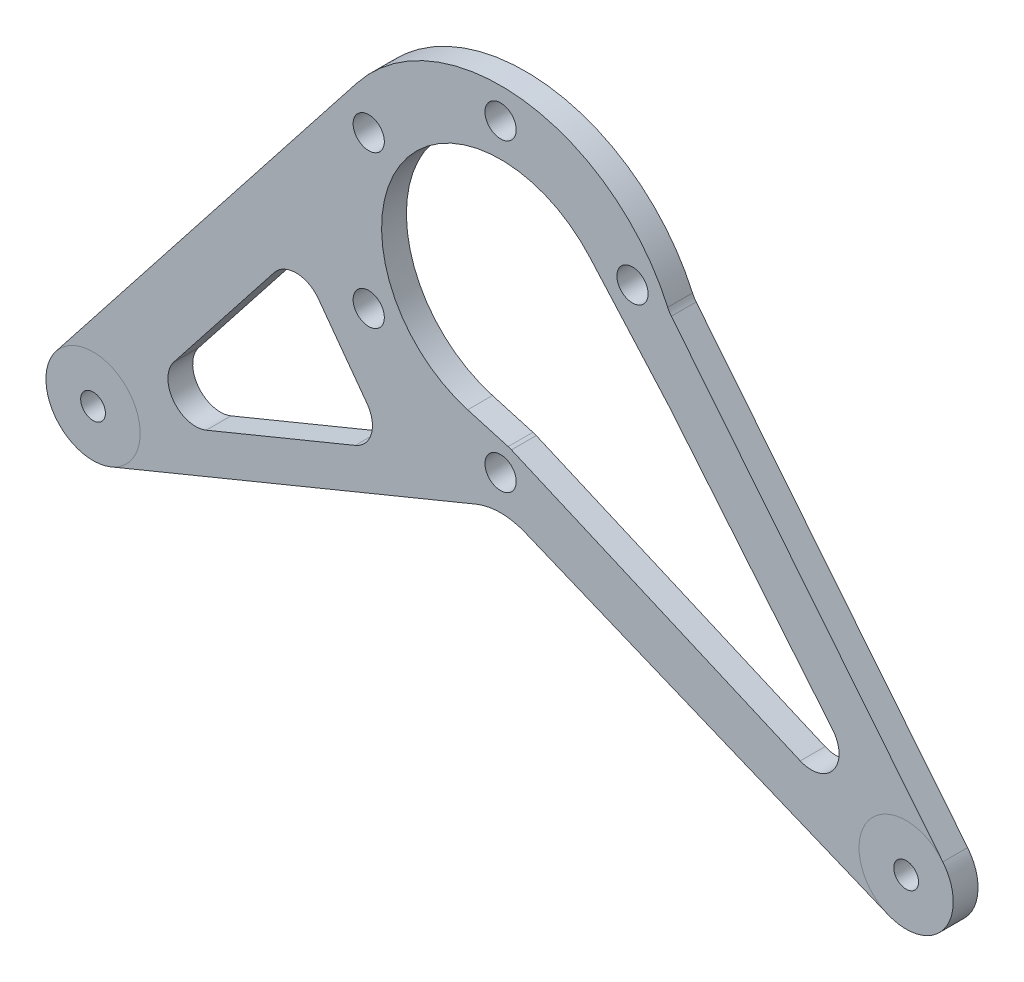
from build123d import *

# Parameters (mm, degrees)
SKETCH3_R           = 4
SKETCH3_R_2         = 3.175
BOSS_EXTRUDE1_DEPTH = 6.35


with BuildPart() as part:
    # Sketch3 → Boss-Extrude1 (new body)
    with BuildSketch(Plane.XY):
        with BuildLine():
            ThreePointArc((-54.344755215, 14.159551399), (-91.363790432, 41.595955293), (-133.974414464, 24.060278895))
            Line((-133.974414464, 24.060278895), (-211.005412605, -73.916742383))
            ThreePointArc((-211.005412605, -73.916742383), (-211.144018552, -88.650897892), (-196.929213693, -92.530829979))
            Line((-196.929213693, -92.530829979), (-103.422476429, -54.04933414))
            ThreePointArc((-103.422476429, -54.04933414), (-97.145595861, -52.808695879), (-90.869059624, -54.05107498))
            Line((-90.869059624, -54.05107498), (2.122974069, -92.350913963))
            ThreePointArc((2.122974069, -92.350913963), (16.383743715, -88.415214787), (16.111301916, -73.623830322))
            Line((16.111301916, -73.623830322), (-53.413545275, 12.636035393))
            ThreePointArc((-53.413545275, 12.636035393), (-53.928639798, 13.36754418), (-54.344755215, 14.159551399))
        make_face()
        with BuildLine():
            ThreePointArc((-94.365331084, -37.471342529), (-94.782391681, -37.306590994), (-95.20914515, -37.168880842))
            Line((-95.20914515, -37.168880842), (-105.570837866, -34.188121867))
            ThreePointArc((-105.570837866, -34.188121867), (-122.920802355, 11.370636159), (-74.330134016, 15.316349154))
            Line((-74.330134016, 15.316349154), (-54.078953085, -7.541638988))
            ThreePointArc((-54.078953085, -7.541638988), (-54.00749546, -7.623730088), (-53.937484416, -7.707058323))
            Line((-53.937484416, -7.707058323), (-12.08621589, -58.41284178))
            ThreePointArc((-12.08621589, -58.41284178), (-11.885929876, -67.212968778), (-20.394707026, -69.467533275))
            Line((-20.394707026, -69.467533275), (-94.365331084, -37.471342529))
        make_face(mode=Mode.SUBTRACT)
        with BuildLine():
            ThreePointArc((-172.528906448, -72.18914022), (-180.908159839, -69.902022358), (-180.826455281, -61.216625426))
            Line((-180.826455281, -61.216625426), (-155.117076369, -28.516434264))
            ThreePointArc((-155.117076369, -28.516434264), (-149.40547172, -25.801135391), (-143.78928279, -28.708659687))
            Line((-143.78928279, -28.708659687), (-131.33676671, -45.703813477))
            ThreePointArc((-131.33676671, -45.703813477), (-130.226967626, -51.831800551), (-134.367011458, -56.484102848))
            Line((-134.367011458, -56.484102848), (-172.528906448, -72.18914022))
        make_face(mode=Mode.SUBTRACT)
        with Locations((-130.919350653, -24.396060329)):
            Circle(SKETCH3_R, mode=Mode.SUBTRACT)
        with Locations((-97.144359905, -43.896060329)):
            Circle(SKETCH3_R, mode=Mode.SUBTRACT)
        with Locations((-130.919350653, 14.603939671)):
            Circle(SKETCH3_R, mode=Mode.SUBTRACT)
        with Locations((-63.369369158, 14.603939671)):
            Circle(SKETCH3_R, mode=Mode.SUBTRACT)
        with Locations((-97.144359905, 34.103939671)):
            Circle(SKETCH3_R, mode=Mode.SUBTRACT)
        with Locations((6.717643784, -81.195052938)):
            Circle(SKETCH3_R_2, mode=Mode.SUBTRACT)
        with Locations((-201.520789163, -81.373695056)):
            Circle(SKETCH3_R_2, mode=Mode.SUBTRACT)
    extrude(amount=BOSS_EXTRUDE1_DEPTH)


solid = part.part
